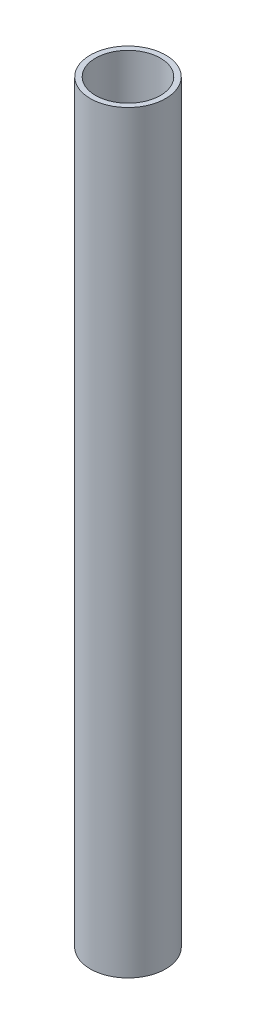
from build123d import *

# Parameters (mm, degrees)
SKETCH_1_R      = 25
SKETCH_1_R_2    = 21.5
EXTRUDE_1_DEPTH = 500


with BuildPart() as part:
    # Эскиз1 → Вытянуть-Тонкостенный1 (new body)
    with BuildSketch(Plane(origin=(0, 0, 0), x_dir=(1, 0, 0), z_dir=(0, 1, 0))):
        Circle(SKETCH_1_R)
        Circle(SKETCH_1_R_2, mode=Mode.SUBTRACT)
    extrude(amount=EXTRUDE_1_DEPTH)


solid = part.part
